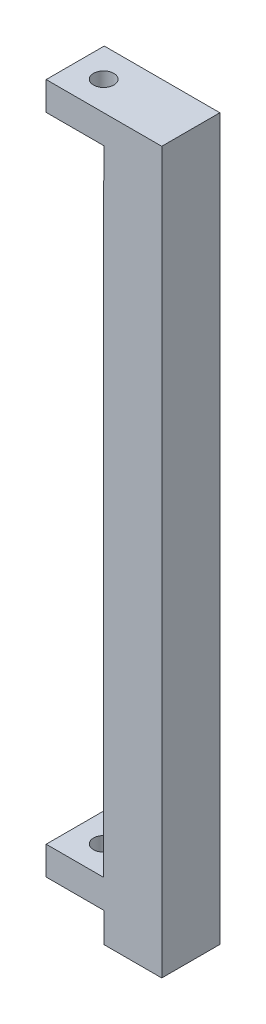
from build123d import *

# Parameters (mm, degrees)
BOSS_EXTRUDE1_DEPTH = 10
CUT_EXTRUDE1_DEPTH  = 11
SKETCH3_R           = 1.75
CUT_EXTRUDE2_DEPTH  = 119.9


with BuildPart() as part:
    # Sketch1 → Boss-Extrude1 (new body)
    with BuildSketch(Plane.XY):
        Polygon((0, 0), (0, 5), (-10, 5), (-10, 10), (0, 10), (0, 119), (-10, 119), (-10, 124), (10, 124), (10, 0), align=None)
    extrude(amount=-BOSS_EXTRUDE1_DEPTH)

    # Sketch2 → Cut-Extrude1 (cut, through all)
    with BuildSketch(Plane.XY):
        Polygon((-10, 10), (-10, 5), (0, 5), (0, 0), (0.1, 0), (0.1, 5.1), (-9.9, 5.1), (-9.9, 10), align=None)
        Polygon((-10, 124), (-10, 119), (0, 119), (0, 113.9), (0.1, 113.9), (0.1, 119.1), (-9.9, 119.1), (-9.9, 124), align=None)
    extrude(amount=-CUT_EXTRUDE1_DEPTH, mode=Mode.SUBTRACT)

    # Sketch3 → Cut-Extrude2 (cut, through all)
    with BuildSketch(Plane.XZ.offset(-5.1)):
        with Locations((-5, -5)):
            Circle(SKETCH3_R)
    extrude(amount=-CUT_EXTRUDE2_DEPTH, mode=Mode.SUBTRACT)


solid = part.part
